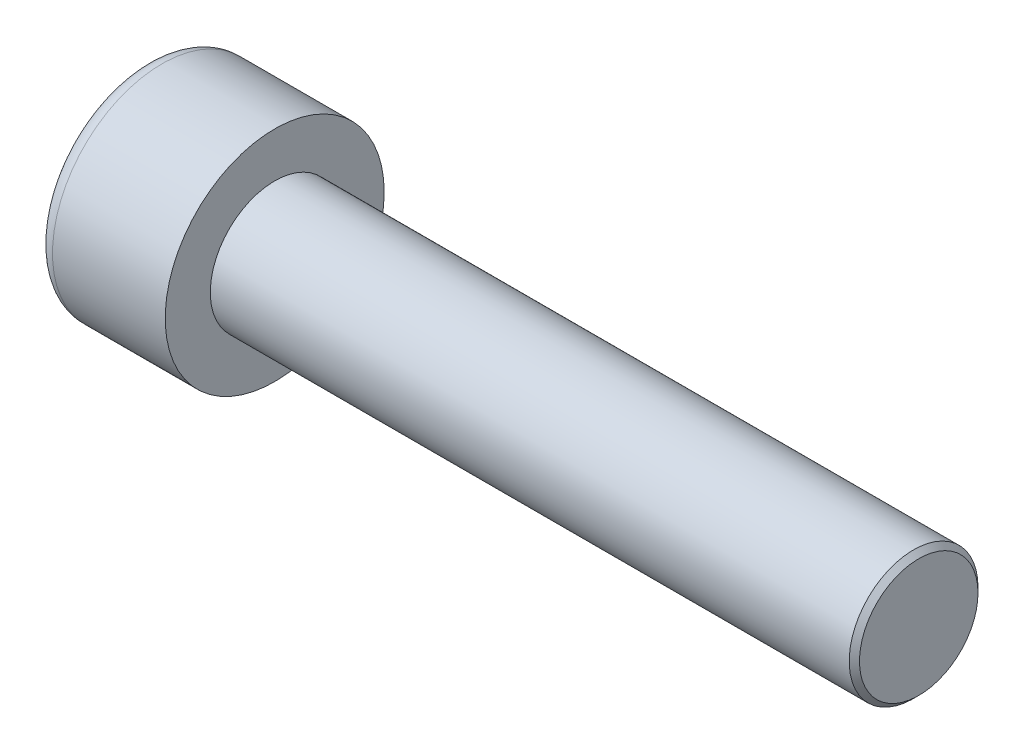
from build123d import *

# Parameters (mm, degrees)
SKETCH1_R           = 4.25
BASEHEAD_DEPTH      = 5
SKETCH2_R           = 2.5
BASEBODY_DEPTH      = 25
HEXAGONSOCKET_DEPTH = 2.5
TOPFILLET_R         = 0.625
CHAMFER1_SIZE       = 0.2


with BuildPart() as part:
    # Sketch1 → BaseHead (new body)
    with BuildSketch(Plane(origin=(0, 0, 0), x_dir=(0, 0, -1), z_dir=(1, 0, 0))):
        Circle(SKETCH1_R)
    extrude(amount=BASEHEAD_DEPTH)

    # Sketch2 → BaseBody (add)
    with BuildSketch(Plane(origin=(5, 0, 0), x_dir=(0, 0, -1), z_dir=(1, 0, 0))):
        Circle(SKETCH2_R)
    extrude(amount=BASEBODY_DEPTH)

    # Sketch3 → HexagonSocket (cut)
    with BuildSketch(Plane(origin=(0, 0, 0), x_dir=(0, 0, -1), z_dir=(1, 0, 0))):
        Polygon((2.309401077, 0), (1.154700538, 2), (-1.154700538, 2), (-2.309401077, 0), (-1.154700538, -2), (1.154700538, -2), align=None)
    extrude(amount=HEXAGONSOCKET_DEPTH, mode=Mode.SUBTRACT)

    # Sketch4 → Cut-Revolve1 (revolve, cut)
    with BuildSketch(Plane(origin=(-4.19613823, 0.75, 0), x_dir=(-1, 0, 0), z_dir=(0, 0, 1))):
        Polygon((-6.69613823, 2.75), (-7.850838768, 0.75), (-6.69613823, 0.75), align=None)
    revolve(axis=Axis((0.838992387, 0, 0), (-1, 0, 0)), mode=Mode.SUBTRACT)

    # TopFillet
    topfillet_edges = [part.edges().sort_by_distance(p)[0] for p in [
        (0, 0, 4.25),
    ]]
    fillet(topfillet_edges, radius=TOPFILLET_R)

    # Chamfer1
    chamfer1_edges = [part.edges().sort_by_distance(p)[0] for p in [
        (30, 0, 2.5),
    ]]
    chamfer(chamfer1_edges, length=CHAMFER1_SIZE)


solid = part.part
